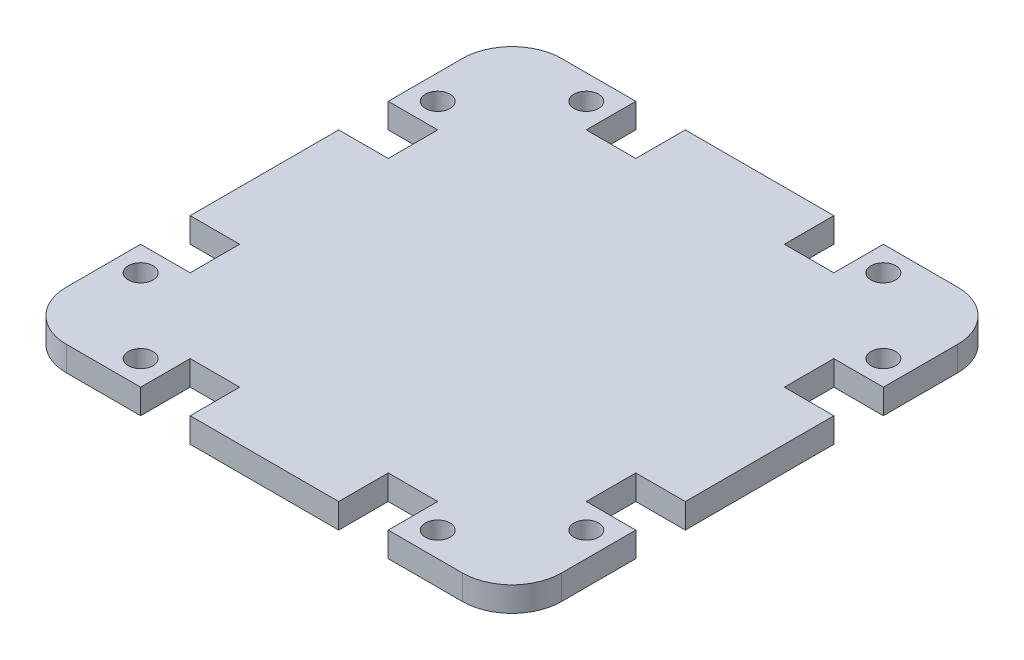
from build123d import *

# Parameters (mm, degrees)
SKETCH1_R           = 2.5
BOSS_EXTRUDE1_DEPTH = 5


with BuildPart() as part:
    # Sketch1 → Boss-Extrude1 (new body)
    with BuildSketch(Plane(origin=(0, 0, 0), x_dir=(1, 0, 0), z_dir=(0, 1, 0))):
        with BuildLine():
            Line((25, -50), (40, -50))
            ThreePointArc((40, -50), (47.071067812, -47.071067812), (50, -40))
            Line((50, -40), (50, -25))
            Line((50, -25), (40, -25))
            Line((40, -25), (40, -15))
            Line((40, -15), (50, -15))
            Line((50, -15), (50, 15))
            Line((50, 15), (40, 15))
            Line((40, 15), (40, 25))
            Line((40, 25), (50, 25))
            Line((50, 25), (50, 40))
            ThreePointArc((50, 40), (47.071067812, 47.071067812), (40, 50))
            Line((40, 50), (30, 50))
            Line((30, 50), (25, 50))
            Line((25, 50), (25, 40))
            Line((25, 40), (15, 40))
            Line((15, 40), (15, 50))
            Line((15, 50), (-15, 50))
            Line((-15, 50), (-15, 40))
            Line((-15, 40), (-25, 40))
            Line((-25, 40), (-25, 50))
            Line((-25, 50), (-40, 50))
            ThreePointArc((-40, 50), (-47.071067812, 47.071067812), (-50, 40))
            Line((-50, 40), (-50, 25))
            Line((-50, 25), (-40, 25))
            Line((-40, 25), (-40, 15))
            Line((-40, 15), (-50, 15))
            Line((-50, 15), (-50, -15))
            Line((-50, -15), (-40, -15))
            Line((-40, -15), (-40, -25))
            Line((-40, -25), (-50, -25))
            Line((-50, -25), (-50, -40))
            ThreePointArc((-50, -40), (-47.071067812, -47.071067812), (-40, -50))
            Line((-40, -50), (-25, -50))
            Line((-25, -50), (-25, -40))
            Line((-25, -40), (-15, -40))
            Line((-15, -40), (-15, -50))
            Line((-15, -50), (15, -50))
            Line((15, -50), (15, -40))
            Line((15, -40), (25, -40))
            Line((25, -40), (25, -50))
        make_face()
        with Locations((-30, -45)):
            Circle(SKETCH1_R, mode=Mode.SUBTRACT)
        with Locations((-45, -30)):
            Circle(SKETCH1_R, mode=Mode.SUBTRACT)
        with Locations((30, -45)):
            Circle(SKETCH1_R, mode=Mode.SUBTRACT)
        with Locations((45, -30)):
            Circle(SKETCH1_R, mode=Mode.SUBTRACT)
        with Locations((-45, 30)):
            Circle(SKETCH1_R, mode=Mode.SUBTRACT)
        with Locations((-30, 45)):
            Circle(SKETCH1_R, mode=Mode.SUBTRACT)
        with Locations((45, 30)):
            Circle(SKETCH1_R, mode=Mode.SUBTRACT)
        with Locations((30, 45)):
            Circle(SKETCH1_R, mode=Mode.SUBTRACT)
    extrude(amount=BOSS_EXTRUDE1_DEPTH)


solid = part.part
